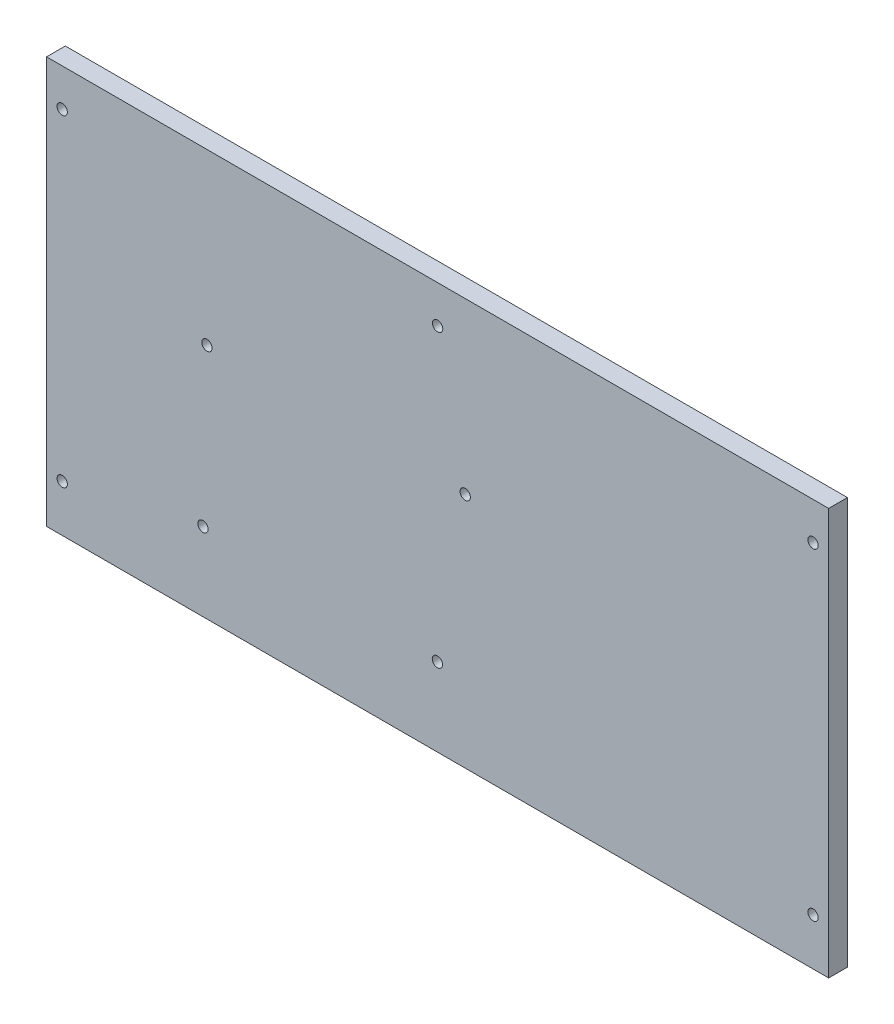
from build123d import *

# Parameters (mm, degrees)
ESBO_O1_W                = 250
ESBO_O1_H                = 130
ESBO_O1_R                = 1.65
RESSALTO_EXTRUS_O1_DEPTH = 6
ESBO_O2_R                = 1.65
CORTE_EXTRUS_O1_DEPTH    = 6


with BuildPart() as part:
    # Esboço1 → Ressalto-extrusão1 (new body)
    with BuildSketch(Plane.XY):
        Rectangle(ESBO_O1_W, ESBO_O1_H)
        with Locations((-120, 53)):
            Circle(ESBO_O1_R, mode=Mode.SUBTRACT)
        with Locations((-120, -50)):
            Circle(ESBO_O1_R, mode=Mode.SUBTRACT)
        with Locations((0, 53)):
            Circle(ESBO_O1_R, mode=Mode.SUBTRACT)
        with Locations((120, -50)):
            Circle(ESBO_O1_R, mode=Mode.SUBTRACT)
        with Locations((120, 53)):
            Circle(ESBO_O1_R, mode=Mode.SUBTRACT)
    extrude(amount=RESSALTO_EXTRUS_O1_DEPTH)

    # Esboço2 → Corte-extrusão1 (cut)
    with BuildSketch(Plane(origin=(0, 0, 0), x_dir=(-1, 0, 0), z_dir=(0, 0, -1))):
        with Locations((73.73, 10.8)):
            Circle(ESBO_O2_R)
        with Locations((75, -40)):
            Circle(ESBO_O2_R)
        with Locations((0.07, -40)):
            Circle(ESBO_O2_R)
        with Locations((-8.82, 10.8)):
            Circle(ESBO_O2_R)
    extrude(amount=-CORTE_EXTRUS_O1_DEPTH, mode=Mode.SUBTRACT)


solid = part.part
